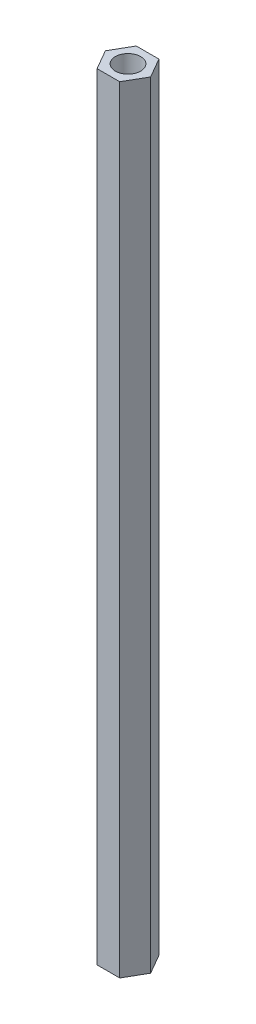
from build123d import *

# Parameters (mm, degrees)
SKETCH1_R           = 1.5
BOSS_EXTRUDE1_DEPTH = 92


with BuildPart() as part:
    # Sketch1 → Boss-Extrude1 (new body)
    with BuildSketch(Plane(origin=(0, 0, 0), x_dir=(1, 0, 0), z_dir=(0, 1, 0))):
        Polygon((1.341379, 2.32333658), (2.682757999, 0), (1.341379, -2.32333658), (-1.341379, -2.32333658), (-2.682757999, 0), (-1.341379, 2.32333658), align=None)
        Circle(SKETCH1_R, mode=Mode.SUBTRACT)
    extrude(amount=BOSS_EXTRUDE1_DEPTH)


solid = part.part
